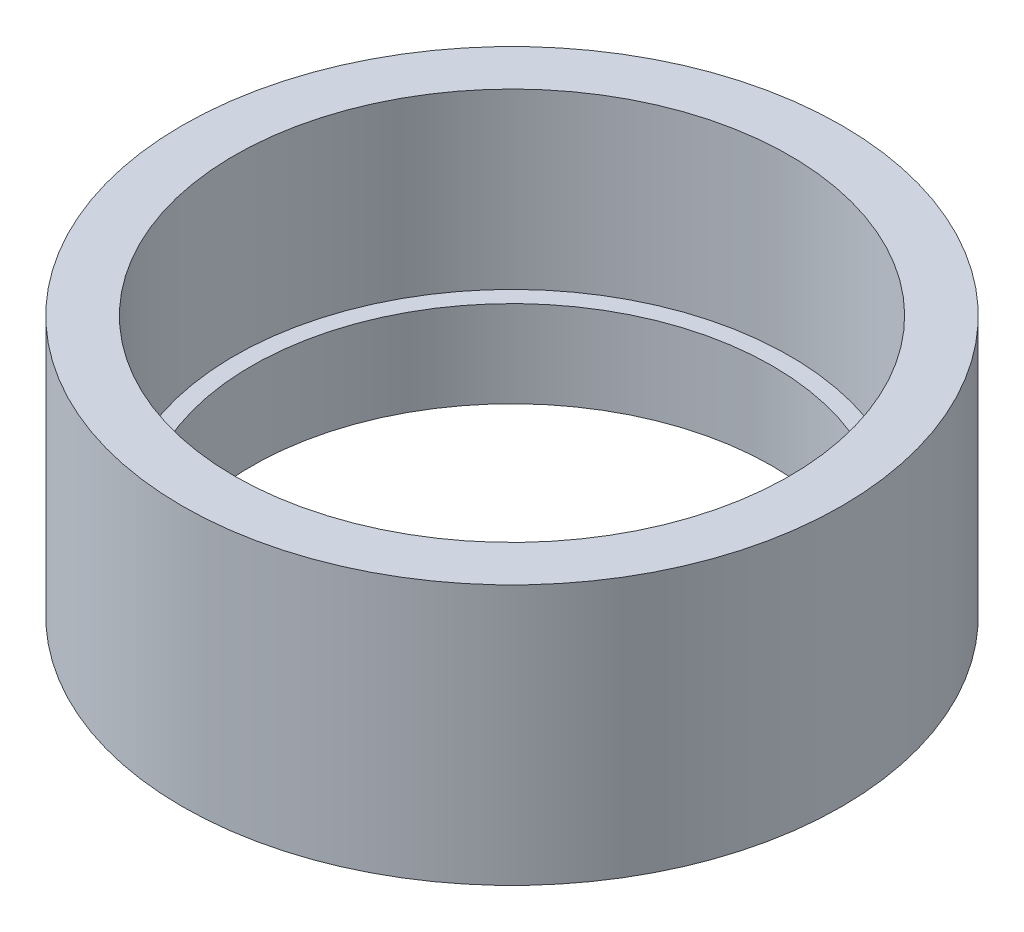
from build123d import *

# Parameters (mm, degrees)
SKETCH1_R           = 3.8
SKETCH1_R_2         = 3
BOSS_EXTRUDE1_DEPTH = 1
SKETCH2_R           = 3.8
SKETCH2_R_2         = 3.2
BOSS_EXTRUDE2_DEPTH = 2


with BuildPart() as part:
    # Sketch1 → Boss-Extrude1 (new body)
    with BuildSketch(Plane(origin=(0, 0, 0), x_dir=(1, 0, 0), z_dir=(0, 1, 0))):
        Circle(SKETCH1_R)
        Circle(SKETCH1_R_2, mode=Mode.SUBTRACT)
    extrude(amount=BOSS_EXTRUDE1_DEPTH)

    # Sketch2 → Boss-Extrude2 (add)
    with BuildSketch(Plane(origin=(0, 1, 0), x_dir=(1, 0, 0), z_dir=(0, 1, 0))):
        Circle(SKETCH2_R)
        Circle(SKETCH2_R_2, mode=Mode.SUBTRACT)
    extrude(amount=BOSS_EXTRUDE2_DEPTH)


solid = part.part
